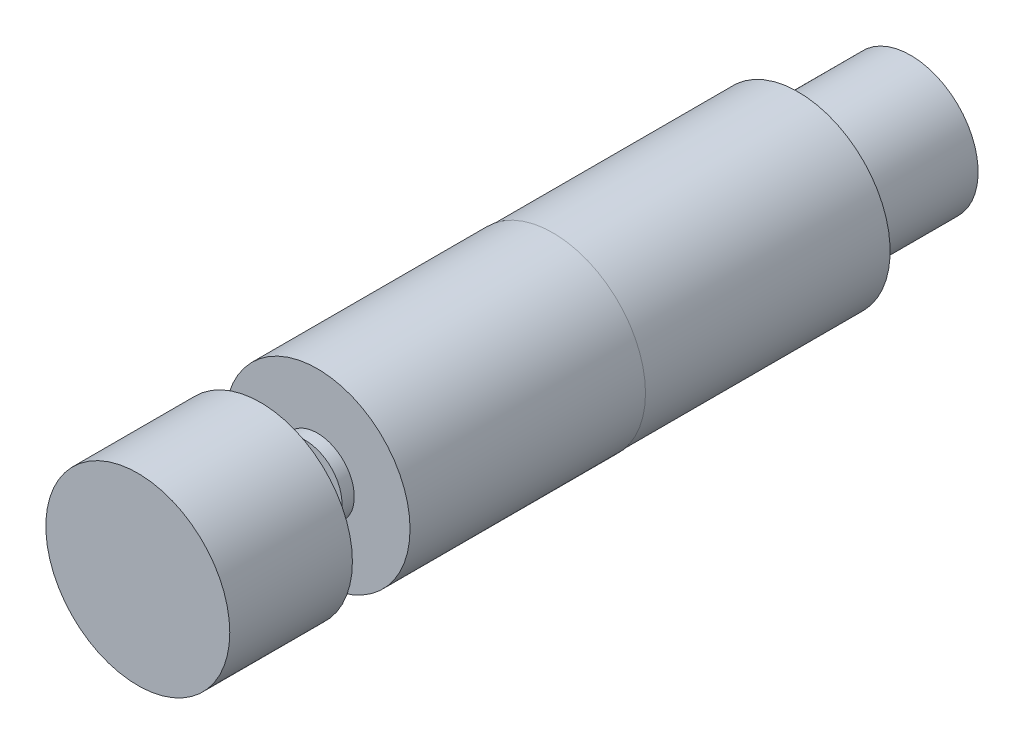
from build123d import *

# Parameters (mm, degrees)
SKETCH1_R                = 15.1
BOSS_EXTRUDE1_DEPTH      = 38.4
SKETCH2_R                = 15
BOSS_EXTRUDE2_DEPTH      = 40
SKETCH3_R                = 6
BOSS_EXTRUDE3_DEPTH      = 2
SKETCH4_R                = 11
BOSS_EXTRUDE4_DEPTH      = 18.35
SKETCH5_R                = 3
BOSS_EXTRUDE5_DEPTH      = 17.3
BOSS_EXTRUDE6_DEPTH      = 10
BOSS_EXTRUDE6_DEPTH_BACK = 10
SKETCH6_R                = 15


with BuildPart() as part:
    # Sketch1 → Boss-Extrude1 (new body)
    with BuildSketch(Plane.XY):
        Circle(SKETCH1_R)
    extrude(amount=BOSS_EXTRUDE1_DEPTH)

    # Sketch3 → Boss-Extrude3 (add)
    with BuildSketch(Plane.XY.offset(38.4)):
        Circle(SKETCH3_R)
    extrude(amount=BOSS_EXTRUDE3_DEPTH)


with BuildPart() as body_2:
    # Sketch2 → Boss-Extrude2 (new body)
    with BuildSketch(Plane(origin=(0, 0, 0), x_dir=(-1, 0, 0), z_dir=(0, 0, -1))):
        Circle(SKETCH2_R)
    extrude(amount=BOSS_EXTRUDE2_DEPTH)


with BuildPart() as body_3:
    # Sketch4 → Boss-Extrude4 (new body)
    with BuildSketch(Plane(origin=(0, 0, -40), x_dir=(-1, 0, 0), z_dir=(0, 0, -1))):
        Circle(SKETCH4_R)
    extrude(amount=BOSS_EXTRUDE4_DEPTH)


with BuildPart() as body_4:
    # Sketch5 → Boss-Extrude5 (new body)
    with BuildSketch(Plane.XY.offset(40.4)):
        Circle(SKETCH5_R)
    extrude(amount=BOSS_EXTRUDE5_DEPTH)

    # Sketch6 → Boss-Extrude6 (add, two sides: drawn at the far end of the back side and taken through both)
    with BuildSketch(Plane.XY.offset(57.7).offset(-BOSS_EXTRUDE6_DEPTH_BACK)):
        Circle(SKETCH6_R)
    extrude(amount=BOSS_EXTRUDE6_DEPTH + BOSS_EXTRUDE6_DEPTH_BACK)


solid = Compound([part.part, body_2.part, body_3.part, body_4.part])
